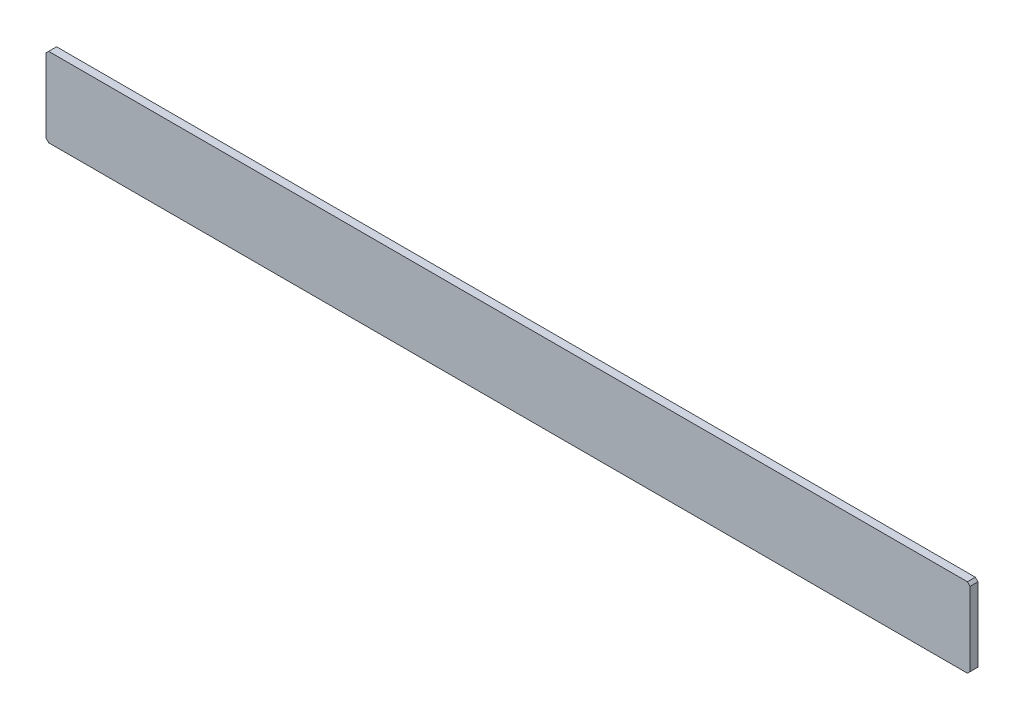
from build123d import *

# Parameters (mm, degrees)
SKETCH_1_W      = 700
SKETCH_1_H      = 60
EXTRUDE_1_DEPTH = 3
CHAMFER_1_SIZE  = 2


with BuildPart() as part:
    # 草图1 → 凸台-拉伸1 (new body, symmetric)
    with BuildSketch(Plane.XY):
        Rectangle(SKETCH_1_W, SKETCH_1_H)
    extrude(amount=EXTRUDE_1_DEPTH, both=True)

    # 倒角1
    chamfer_1_edges = [part.edges().sort_by_distance(p)[0] for p in [
        (-350, 30, 0),
        (350, 30, 0),
        (350, -30, 0),
        (-350, -30, 0),
    ]]
    chamfer(chamfer_1_edges, length=CHAMFER_1_SIZE)


solid = part.part
